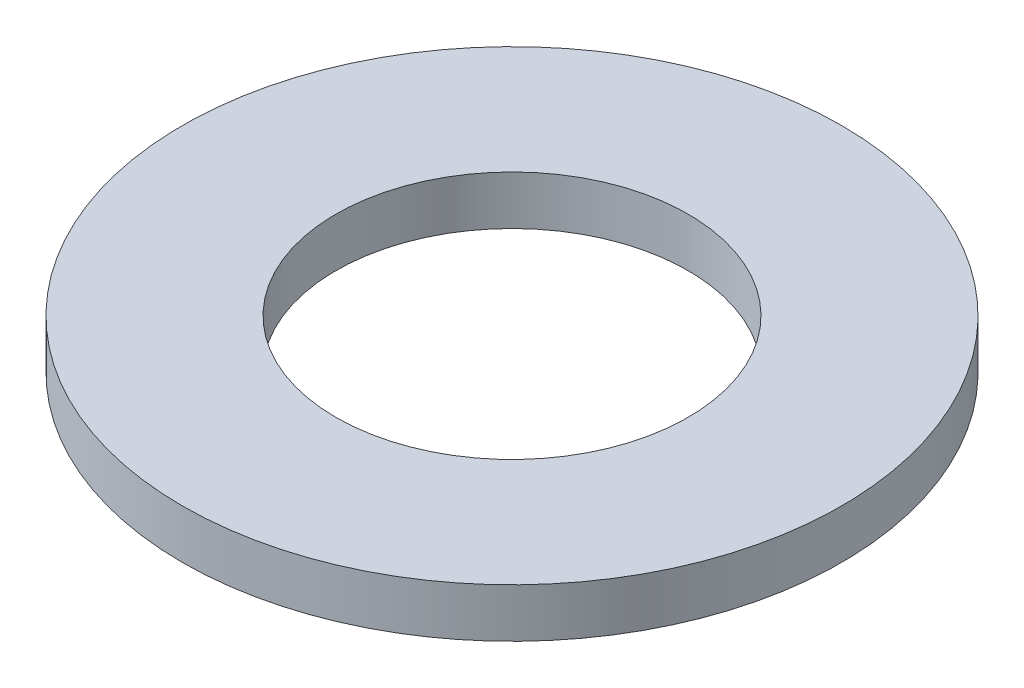
from build123d import *

# Parameters (mm, degrees)
SKETCH1_R           = 22.225
BOSS_EXTRUDE1_DEPTH = 3.302
SKETCH5_R           = 11.8745
CUT_EXTRUDE1_DEPTH  = 4.302


with BuildPart() as part:
    # Sketch1 → Boss-Extrude1 (new body)
    with BuildSketch(Plane(origin=(0, 0, 0), x_dir=(1, 0, 0), z_dir=(0, 1, 0))):
        Circle(SKETCH1_R)
    extrude(amount=BOSS_EXTRUDE1_DEPTH)

    # Sketch5 → Cut-Extrude1 (cut, through all)
    with BuildSketch(Plane(origin=(0, 3.302, 0), x_dir=(-1, 0, 0), z_dir=(0, 1, 0))):
        Circle(SKETCH5_R)
    extrude(amount=-CUT_EXTRUDE1_DEPTH, mode=Mode.SUBTRACT)


solid = part.part
